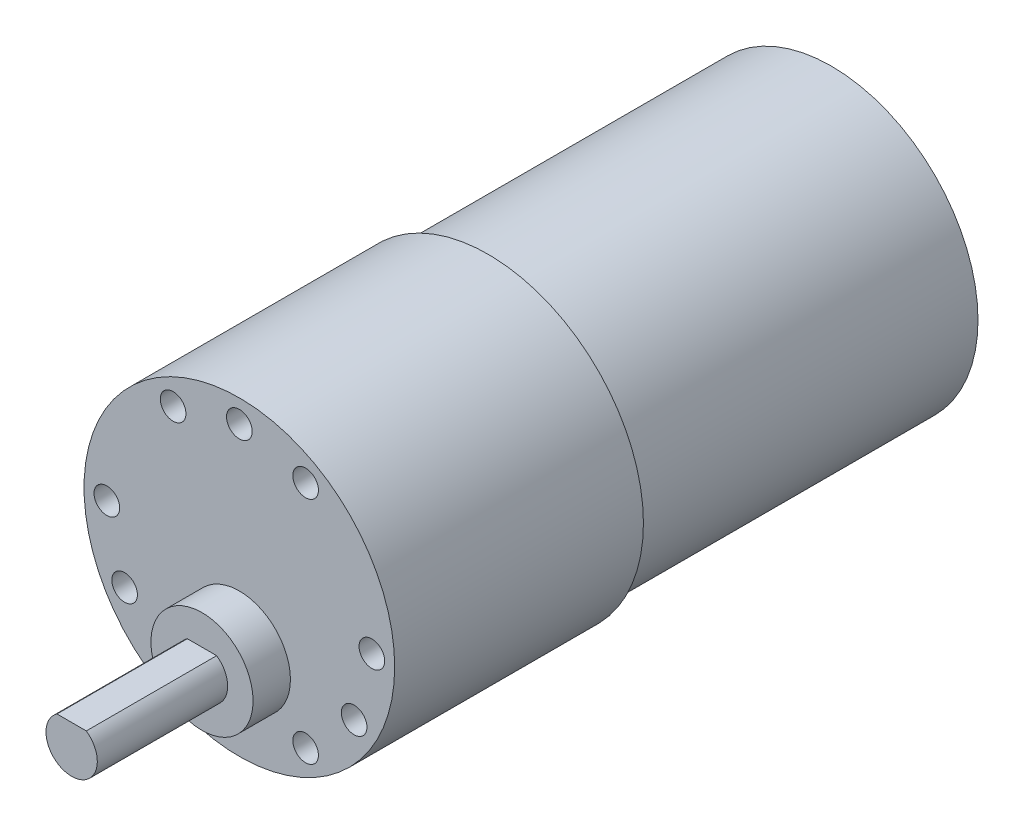
from build123d import *

# Parameters (mm, degrees)
SKETCH1_R           = 18.161
BOSS_EXTRUDE1_DEPTH = 29.083
SKETCH5_R           = 5.969
BOSS_EXTRUDE5_DEPTH = 4.3688
BOSS_EXTRUDE6_DEPTH = 15.24
CIRPATTERN2_COUNT   = 12
SKETCH2_R           = 17.145
BOSS_EXTRUDE2_DEPTH = 40.132
SKETCH3_R           = 3.048
BOSS_EXTRUDE3_DEPTH = 3.81
SKETCH13_R          = 16.637
CUT_EXTRUDE1_DEPTH  = 1.016
SKETCH15_W          = 2.54
SKETCH15_H          = 5.08
SKETCH15_R          = 0.4445
BOSS_EXTRUDE7_DEPTH = 0.254
SKETCH16_W          = 2.54
SKETCH16_H          = 5.08
SKETCH16_R          = 0.678606607
BOSS_EXTRUDE8_DEPTH = 0.254


with BuildPart() as part:
    # Sketch1 → Boss-Extrude1 (new body)
    with BuildSketch(Plane.XY):
        Circle(SKETCH1_R)
    extrude(amount=BOSS_EXTRUDE1_DEPTH)

    # Sketch5 → Boss-Extrude5 (add)
    with BuildSketch(Plane.XY.offset(29.083)):
        with Locations((0, -7.366)):
            Circle(SKETCH5_R)
    extrude(amount=BOSS_EXTRUDE5_DEPTH)

    # Sketch6 → Boss-Extrude6 (add)
    with BuildSketch(Plane.XY.offset(33.4518)):
        with BuildLine():
            Line((-1.715657017, -4.905), (1.715657017, -4.905))
            ThreePointArc((1.715657017, -4.905), (0, -10.366), (-1.715657017, -4.905))
        make_face()
    extrude(amount=BOSS_EXTRUDE6_DEPTH)

    # Sketch12 → Ø3.0mm Dowel Hole1 (revolve, cut)
    with BuildSketch(Plane(origin=(0, 15.494, 29.083), x_dir=(0, -1, 0), z_dir=(1, 0, 0))):
        Polygon((0, 0), (0, 11.061290929), (1.5, 10.16), (1.5, 0), align=None)
    f_3_0mm_dowel_hole1 = revolve(axis=Axis((0, 15.494, 35.433), (0, 0, -1)), mode=Mode.SUBTRACT)

    # CirPattern2: Ø3.0mm Dowel Hole1 ×12 about axis, 3 skipped
    cirpattern2_axis = Axis((0, 0, 0), (0, 0, -1))
    add([f_3_0mm_dowel_hole1.rotate(cirpattern2_axis, i * 360 / CIRPATTERN2_COUNT) for i in range(1, CIRPATTERN2_COUNT) if i not in (2, 6, 10)], mode=Mode.SUBTRACT)

    # Sketch2 → Boss-Extrude2 (add)
    with BuildSketch(Plane(origin=(0, 0, 0), x_dir=(-1, 0, 0), z_dir=(0, 0, -1))):
        Circle(SKETCH2_R)
    extrude(amount=BOSS_EXTRUDE2_DEPTH)

    # Sketch3 → Boss-Extrude3 (add)
    with BuildSketch(Plane(origin=(0, 0, -40.132), x_dir=(-1, 0, 0), z_dir=(0, 0, -1))):
        Circle(SKETCH3_R)
    extrude(amount=BOSS_EXTRUDE3_DEPTH)

    # Sketch13 → Cut-Extrude1 (cut)
    with BuildSketch(Plane(origin=(0, 0, -40.132), x_dir=(-1, 0, 0), z_dir=(0, 0, -1))):
        Circle(SKETCH13_R)
    extrude(amount=-CUT_EXTRUDE1_DEPTH, mode=Mode.SUBTRACT)

    # Sketch15 → Boss-Extrude7 (add, symmetric)
    with BuildSketch(Plane(origin=(0, 0, 0), x_dir=(0.64278761, -0.766044443, 0), z_dir=(0.766044443, 0.64278761, 0))):
        with Locations((10.16, 41.656)):
            Rectangle(SKETCH15_W, SKETCH15_H)
        with Locations((10.16, 42.926)):
            Circle(SKETCH15_R, mode=Mode.SUBTRACT)
    extrude(amount=BOSS_EXTRUDE7_DEPTH, both=True)

    # Sketch16 → Boss-Extrude8 (add, symmetric)
    with BuildSketch(Plane(origin=(0, 0, 0), x_dir=(-0.258819045, -0.965925826, 0), z_dir=(0.965925826, -0.258819045, 0))):
        with Locations((11.43, 41.656)):
            Rectangle(SKETCH16_W, SKETCH16_H)
        with Locations((11.43, 42.926)):
            Circle(SKETCH16_R, mode=Mode.SUBTRACT)
    extrude(amount=BOSS_EXTRUDE8_DEPTH, both=True)


solid = part.part
